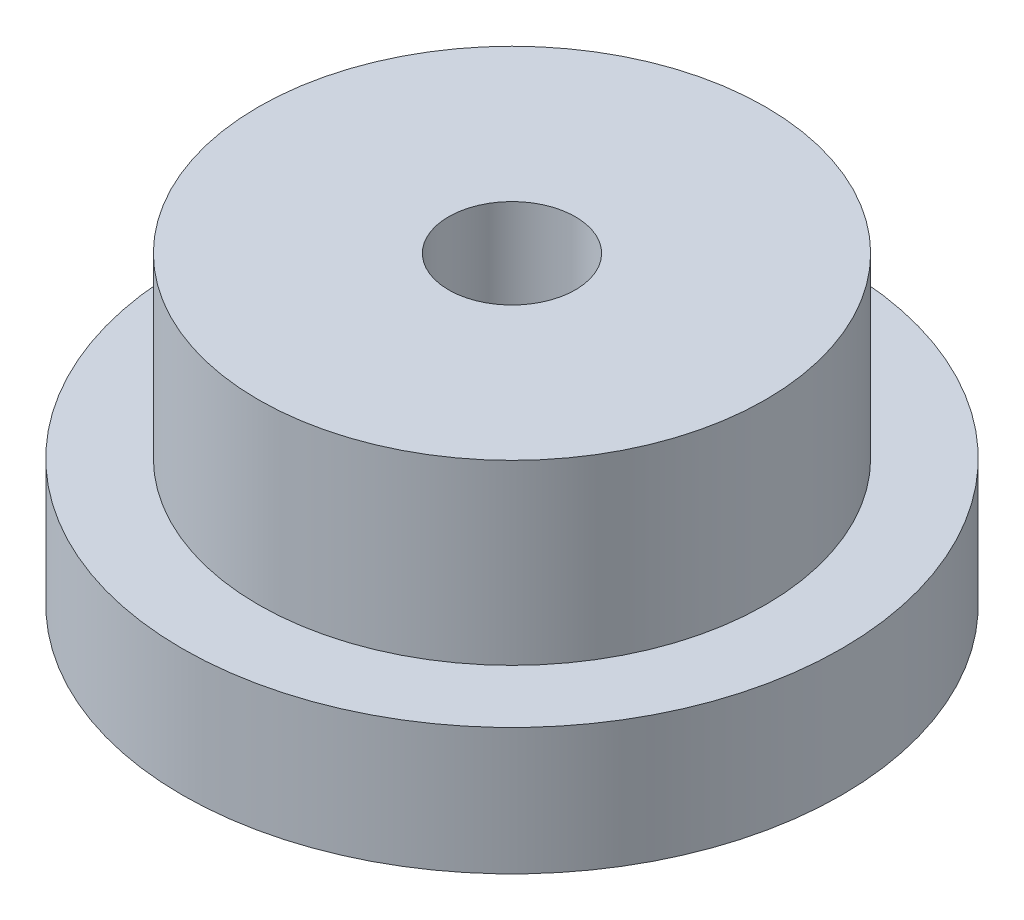
from build123d import *

# Parameters (mm, degrees)
SKETCH1_R           = 13
SKETCH1_R_2         = 2.5
BOSS_EXTRUDE1_DEPTH = 5
SKETCH2_R           = 10
SKETCH2_R_2         = 2.5
BOSS_EXTRUDE2_DEPTH = 7


with BuildPart() as part:
    # Sketch1 → Boss-Extrude1 (new body)
    with BuildSketch(Plane(origin=(0, 0, 0), x_dir=(1, 0, 0), z_dir=(0, 1, 0))):
        Circle(SKETCH1_R)
        Circle(SKETCH1_R_2, mode=Mode.SUBTRACT)
    extrude(amount=BOSS_EXTRUDE1_DEPTH)

    # Sketch2 → Boss-Extrude2 (add)
    with BuildSketch(Plane(origin=(0, 5, 0), x_dir=(1, 0, 0), z_dir=(0, 1, 0))):
        Circle(SKETCH2_R)
        Circle(SKETCH2_R_2, mode=Mode.SUBTRACT)
    extrude(amount=BOSS_EXTRUDE2_DEPTH)


solid = part.part
